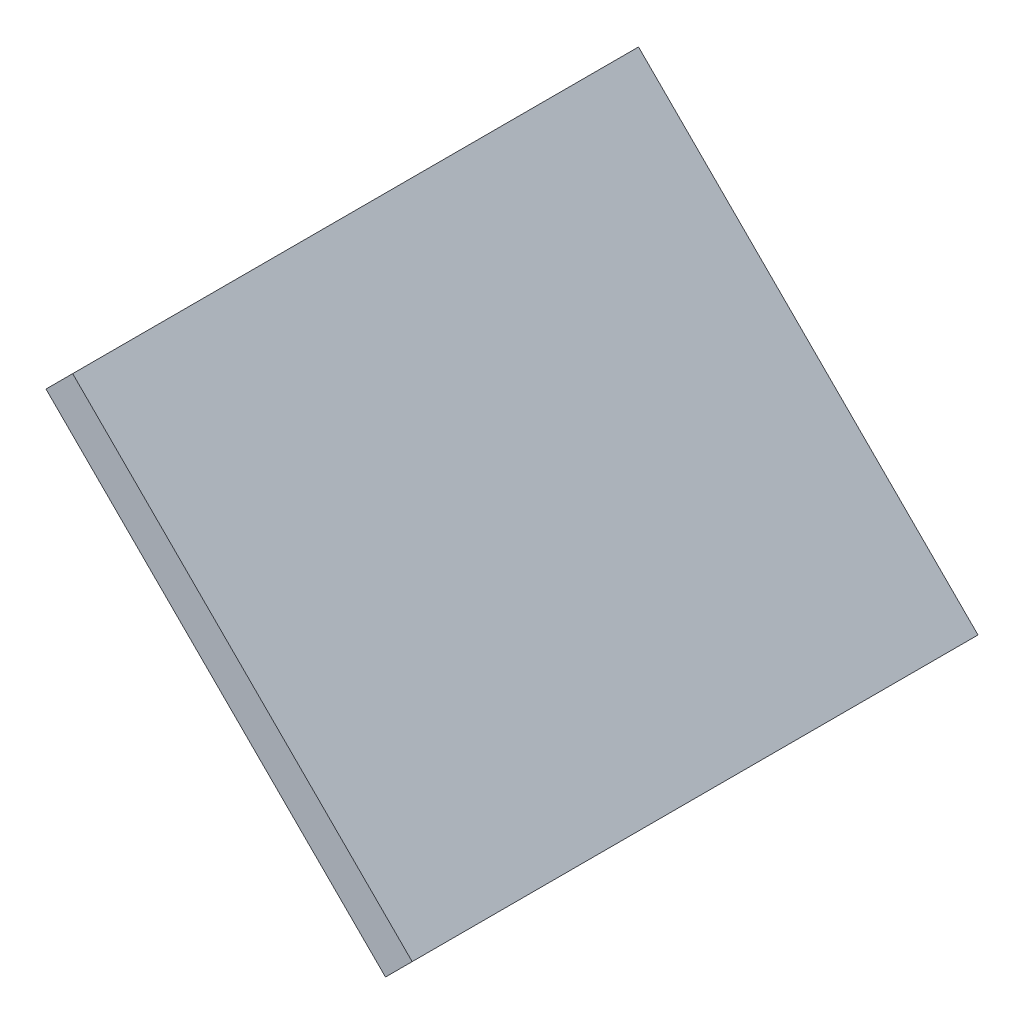
from build123d import *

# Parameters (mm, degrees)
EXTRUDE_THIN1_DEPTH = 75


with BuildPart() as part:
    # Sketch1 → Extrude-Thin1 (new body, symmetric)
    with BuildSketch(Plane.XY):
        Polygon((48.535533906, -41.464466094), (-41.464466094, 48.535533906), (-48.535533906, 41.464466094), (41.464466094, -48.535533906), align=None)
    extrude(amount=EXTRUDE_THIN1_DEPTH, both=True)


solid = part.part
